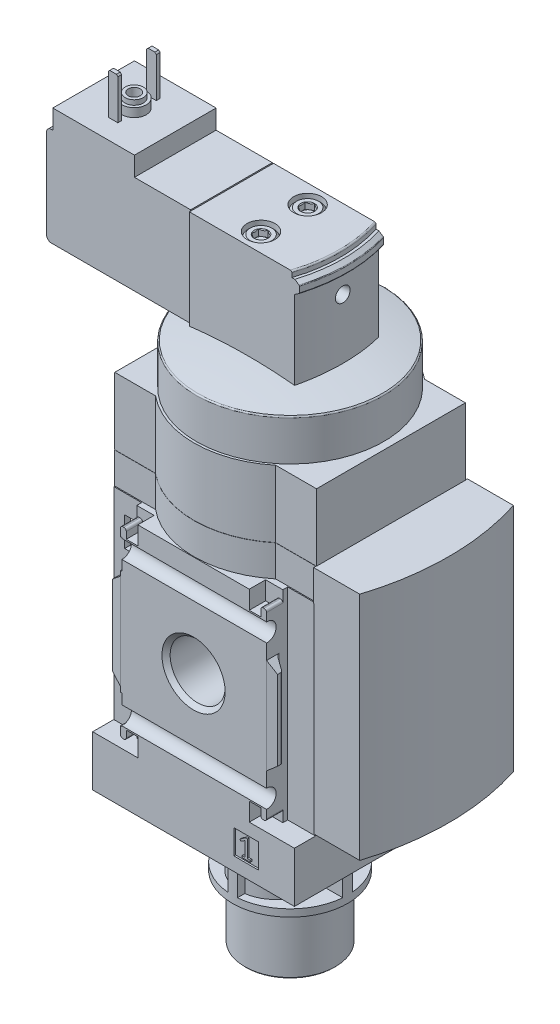
from build123d import *

# Parameters (mm, degrees)
BOSS_EXTRUDE1_DEPTH          = 49.5
BOSS_EXTRUDE2_DEPTH          = 20.1
BOSS_EXTRUDE2_DEPTH_BACK     = 20.1
SKETCH2_W                    = 42
SKETCH2_H                    = 42
SKETCH3_W                    = 42
SKETCH3_H                    = 40.2
BOSS_EXTRUDE3_DEPTH          = 10.5
SKETCH4_W                    = 46
SKETCH4_H                    = 40
CUT_EXTRUDE1_DEPTH           = 14
BOSS_EXTRUDE4_DEPTH          = 13.96
BOSS_EXTRUDE5_DEPTH          = 48
SKETCH9_W                    = 5.1
SKETCH9_H                    = 5.1
CUT_EXTRUDE2_DEPTH           = 0.35
SKETCH10_W                   = 5.1
SKETCH10_H                   = 5.1
CUT_EXTRUDE3_DEPTH           = 0.35
CUT_EXTRUDE4_DEPTH           = 25
CUT_EXTRUDE4_DEPTH_BACK      = 25
CUT_EXTRUDE5_DEPTH           = 25
CUT_EXTRUDE5_DEPTH_BACK      = 25
CUT_EXTRUDE6_DEPTH           = 3.4
CUT_EXTRUDE6_DEPTH_BACK      = 3.4
CUT_EXTRUDE7_DEPTH           = 3.4
CUT_EXTRUDE7_DEPTH_BACK      = 3.4
CUT_EXTRUDE8_DEPTH           = 3.4
CUT_EXTRUDE8_DEPTH_BACK      = 3.4
CUT_EXTRUDE9_DEPTH           = 3.4
CUT_EXTRUDE9_DEPTH_BACK      = 3.4
CUT_EXTRUDE10_DEPTH          = 21
CUT_EXTRUDE10_DEPTH_BACK     = 21
CUT_EXTRUDE11_DEPTH          = 21
CUT_EXTRUDE11_DEPTH_BACK     = 21
SKETCH19_W                   = 4
SKETCH19_H                   = 4
BOSS_EXTRUDE6_DEPTH          = 15
BOSS_EXTRUDE7_DEPTH          = 8.75
BOSS_EXTRUDE7_DEPTH_BACK     = 8.75
CUT_EXTRUDE12_DEPTH          = 25
SKETCH22_W                   = 3
SKETCH22_H                   = 21
CUT_REVOLVE3_ANGLE           = 20
CUT_REVOLVE3_OTHER_WAY_ANGLE = 20
REVOLVE1_ANGLE               = 20
REVOLVE1_OTHER_WAY_ANGLE     = 20
CUT_EXTRUDE13_DEPTH          = 5
CUT_REVOLVE5_ANGLE           = 20
CUT_REVOLVE5_OTHER_WAY_ANGLE = 20
BOSS_EXTRUDE8_DEPTH          = 0.4
BOSS_EXTRUDE8_DEPTH_BACK     = 0.4
BOSS_EXTRUDE9_DEPTH          = 0.4
BOSS_EXTRUDE9_DEPTH_BACK     = 0.4
CUT_EXTRUDE14_DEPTH          = 1.3
CUT_EXTRUDE15_DEPTH          = 1.3
BOSS_EXTRUDE10_DEPTH         = 14
CUT_EXTRUDE16_DEPTH          = 22
CUT_EXTRUDE16_DEPTH_BACK     = 22
SKETCH39_W                   = 3.81
SKETCH39_H                   = 6.07
CUT_EXTRUDE17_DEPTH          = 22
CUT_EXTRUDE17_DEPTH_BACK     = 22
SKETCH40_W                   = 3.81
SKETCH40_H                   = 6.07
CUT_EXTRUDE18_DEPTH          = 11
CUT_EXTRUDE18_DEPTH_BACK     = 11
SKETCH41_W                   = 29
SKETCH41_H                   = 37.9
BOSS_EXTRUDE11_DEPTH         = 19
BOSS_EXTRUDE11_DEPTH_BACK    = 19
BOSS_EXTRUDE12_DEPTH         = 9
BOSS_EXTRUDE13_DEPTH         = 9
SKETCH45_R                   = 3.05
BOSS_EXTRUDE14_DEPTH         = 5


with BuildPart() as part:
    # Sketch1 → Boss-Extrude1 (new body)
    with BuildSketch(Plane(origin=(0, -8, 0), x_dir=(1, 0, 0), z_dir=(0, 1, 0))):
        with BuildLine():
            Line((-21, -15.5), (-12.5, -15.5))
            ThreePointArc((-12.5, -15.5), (0, -20), (12.5, -15.5))
            Line((12.5, -15.5), (21, -15.5))
            Line((21, -15.5), (21, 15.5))
            Line((21, 15.5), (12.5, 15.5))
            ThreePointArc((12.5, 15.5), (0, 20), (-12.5, 15.5))
            Line((-12.5, 15.5), (-21, 15.5))
            Line((-21, 15.5), (-21, -15.5))
        make_face()
    extrude(amount=BOSS_EXTRUDE1_DEPTH)

    # Sketch2 → Boss-Extrude2 (add, two sides: drawn at the far end of the back side and taken through both)
    with BuildSketch(Plane.XY.offset(-BOSS_EXTRUDE2_DEPTH_BACK)):
        Rectangle(SKETCH2_W, SKETCH2_H)
    extrude(amount=BOSS_EXTRUDE2_DEPTH + BOSS_EXTRUDE2_DEPTH_BACK)

    # Sketch3 → Boss-Extrude3 (add)
    with BuildSketch(Plane(origin=(0, -31.5, 0), x_dir=(1, 0, 0), z_dir=(0, 1, 0))):
        Rectangle(SKETCH3_W, SKETCH3_H)
    extrude(amount=BOSS_EXTRUDE3_DEPTH)

    # Sketch4 → Cut-Extrude1 (cut)
    with BuildSketch(Plane(origin=(0, 27.5, 0), x_dir=(1, 0, 0), z_dir=(0, 1, 0))):
        Rectangle(SKETCH4_W, SKETCH4_H)
        with BuildLine():
            Line((-20.58, -15.19), (-12.25, -15.19))
            ThreePointArc((-12.25, -15.19), (0, -19.6), (12.25, -15.19))
            Line((12.25, -15.19), (20.58, -15.19))
            Line((20.58, -15.19), (20.58, 15.19))
            Line((20.58, 15.19), (12.25, 15.19))
            ThreePointArc((12.25, 15.19), (0, 19.6), (-12.25, 15.19))
            Line((-12.25, 15.19), (-20.58, 15.19))
            Line((-20.58, 15.19), (-20.58, -15.19))
        make_face(mode=Mode.SUBTRACT)
    extrude(amount=CUT_EXTRUDE1_DEPTH, mode=Mode.SUBTRACT)

    # Sketch5 → Boss-Extrude4 (add)
    with BuildSketch(Plane(origin=(0, 27.54, 0), x_dir=(1, 0, 0), z_dir=(0, 1, 0))):
        with BuildLine():
            Line((-21, -15.5), (-12.5, -15.5))
            ThreePointArc((-12.5, -15.5), (0, -20), (12.5, -15.5))
            Line((12.5, -15.5), (21, -15.5))
            Line((21, -15.5), (21, 15.5))
            Line((21, 15.5), (12.5, 15.5))
            ThreePointArc((12.5, 15.5), (0, 20), (-12.5, 15.5))
            Line((-12.5, 15.5), (-21, 15.5))
            Line((-21, 15.5), (-21, -15.5))
        make_face()
    extrude(amount=BOSS_EXTRUDE4_DEPTH)

    # Sketch6 → Boss-Extrude5 (add)
    with BuildSketch(Plane(origin=(0, 27.5, 0), x_dir=(1, 0, 0), z_dir=(0, 1, 0))):
        with BuildLine():
            Line((20.9, -16), (30.5, -16))
            ThreePointArc((30.5, -16), (33, 0), (30.5, 16))
            Line((30.5, 16), (20.9, 16))
            Line((20.9, 16), (20.9, -16))
        make_face()
    extrude(amount=-BOSS_EXTRUDE5_DEPTH)

    # Sketch7 → Cut-Revolve1 (revolve, cut)
    with BuildSketch(Plane(origin=(0, 0, 0), x_dir=(0, 0, -1), z_dir=(1, 0, 0))):
        Polygon((-20.1, 0), (-20.1, 6.5785), (-19.244, 5.7225), (-7.799, 5.7225), (-6.943, 6.5785), (-6.943, 0), align=None)
    revolve(axis=Axis((0, 0, 6.943), (0, 0, 1)), mode=Mode.SUBTRACT)

    # Sketch8 → Cut-Revolve2 (revolve, cut)
    with BuildSketch(Plane(origin=(0, 0, 0), x_dir=(0, 0, -1), z_dir=(1, 0, 0))):
        Polygon((6.943, 0), (6.943, 6.5785), (7.799, 5.7225), (19.244, 5.7225), (20.1, 6.5785), (20.1, 0), align=None)
    revolve(axis=Axis((0, 0, -20.1), (0, 0, 1)), mode=Mode.SUBTRACT)

    # Sketch9 → Cut-Extrude2 (cut)
    with BuildSketch(Plane.XY.offset(20.1)):
        with Locations((10.95, -26.14)):
            Rectangle(SKETCH9_W, SKETCH9_H)
        Polygon((9.663200115, -25.02), (9.761292304, -25.275538889), (10.24, -25.062404491), (10.71, -24.78), (10.71, -27.76), (10.1, -27.76), (10.1, -28.14), (11.8, -28.14), (11.8, -27.76), (11.19, -27.76), (11.19, -24.21), (10.82, -24.21), align=None, mode=Mode.SUBTRACT)
    extrude(amount=-CUT_EXTRUDE2_DEPTH, mode=Mode.SUBTRACT)

    # Sketch10 → Cut-Extrude3 (cut)
    with BuildSketch(Plane.XY.offset(-20.1)):
        with Locations((-10.95, -26.14)):
            Rectangle(SKETCH10_W, SKETCH10_H)
        with BuildLine():
            Line((-12.03983262, -25.241503505), (-10.470570303, -27.482642356))
            ThreePointArc((-10.470570303, -27.482642356), (-10.463784424, -27.586174861), (-10.552485507, -27.64))
            Line((-10.552485507, -27.64), (-12.15, -27.64))
            Line((-12.15, -27.64), (-12.15, -28.14))
            Line((-12.15, -28.14), (-9.75, -28.14))
            Line((-9.75, -28.14), (-9.75, -27.64))
            Line((-9.75, -27.64), (-11.575165094, -25.033394109))
            ThreePointArc((-11.575165094, -25.033394109), (-11.592129791, -24.774562847), (-11.370377083, -24.64))
            Line((-11.370377083, -24.64), (-10.75, -24.64))
            ThreePointArc((-10.75, -24.64), (-10.396446609, -24.786446609), (-10.25, -25.14))
            Line((-10.25, -25.14), (-9.75, -25.14))
            ThreePointArc((-9.75, -25.14), (-10.042893219, -24.432893219), (-10.75, -24.14))
            Line((-10.75, -24.14), (-11.466426189, -24.14))
            ThreePointArc((-11.466426189, -24.14), (-12.087333772, -24.516775971), (-12.03983262, -25.241503505))
        make_face(mode=Mode.SUBTRACT)
    extrude(amount=CUT_EXTRUDE3_DEPTH, mode=Mode.SUBTRACT)

    # Sketch11 → Cut-Extrude4 (cut, two sides: drawn at the far end of the back side and taken through both)
    with BuildSketch(Plane(origin=(0, 0, 0), x_dir=(0, 0, -1), z_dir=(1, 0, 0)).offset(-CUT_EXTRUDE4_DEPTH_BACK)):
        with BuildLine():
            Line((21.9, -15), (21.9, 15))
            ThreePointArc((21.9, 15), (18.490033113, 16.153256259), (20.5, 13.166969722))
            Line((20.5, 13.166969722), (20.5, -13.166969722))
            ThreePointArc((20.5, -13.166969722), (18.490033113, -16.153256259), (21.9, -15))
        make_face()
    extrude(amount=CUT_EXTRUDE4_DEPTH + CUT_EXTRUDE4_DEPTH_BACK, mode=Mode.SUBTRACT)

    # Sketch12 → Cut-Extrude5 (cut, two sides: drawn at the far end of the back side and taken through both)
    with BuildSketch(Plane(origin=(0, 0, 0), x_dir=(0, 0, -1), z_dir=(1, 0, 0)).offset(-CUT_EXTRUDE5_DEPTH_BACK)):
        with BuildLine():
            Line((-21.9, 15), (-21.9, -15))
            ThreePointArc((-21.9, -15), (-18.490033113, -16.153256259), (-20.5, -13.166969722))
            Line((-20.5, -13.166969722), (-20.5, 13.166969722))
            ThreePointArc((-20.5, 13.166969722), (-18.490033113, 16.153256259), (-21.9, 15))
        make_face()
    extrude(amount=CUT_EXTRUDE5_DEPTH + CUT_EXTRUDE5_DEPTH_BACK, mode=Mode.SUBTRACT)

    # Sketch13 → Cut-Extrude6 (cut, two sides: drawn at the far end of the back side and taken through both)
    with BuildSketch(Plane.XY.offset(20.1).offset(-CUT_EXTRUDE6_DEPTH_BACK)):
        with BuildLine():
            Line((11.6, 21), (11.6, 17.2))
            Line((11.6, 17.2), (14, 17.2))
            Line((14, 17.2), (14, 18.6))
            ThreePointArc((14, 18.6), (14.146446609, 18.953553391), (14.5, 19.1))
            Line((14.5, 19.1), (14.7, 19.1))
            ThreePointArc((14.7, 19.1), (15.053553391, 18.953553391), (15.2, 18.6))
            Line((15.2, 18.6), (15.2, 9.95))
            Line((15.2, 9.95), (21.5, 4.663672324))
            Line((21.5, 4.663672324), (21.5, -4.663672324))
            Line((21.5, -4.663672324), (15.2, -9.95))
            Line((15.2, -9.95), (15.2, -18.6))
            ThreePointArc((15.2, -18.6), (15.053553391, -18.953553391), (14.7, -19.1))
            Line((14.7, -19.1), (14.5, -19.1))
            ThreePointArc((14.5, -19.1), (14.146446609, -18.953553391), (14, -18.6))
            Line((14, -18.6), (14, -17.2))
            Line((14, -17.2), (11.6, -17.2))
            Line((11.6, -17.2), (11.6, -21))
            Line((11.6, -21), (22, -21))
            Line((22, -21), (22, 21))
            Line((22, 21), (11.6, 21))
        make_face()
    extrude(amount=CUT_EXTRUDE6_DEPTH + CUT_EXTRUDE6_DEPTH_BACK, mode=Mode.SUBTRACT)

    # Sketch14 → Cut-Extrude7 (cut, two sides: drawn at the far end of the back side and taken through both)
    with BuildSketch(Plane.XY.offset(20.1).offset(-CUT_EXTRUDE7_DEPTH_BACK)):
        with BuildLine():
            Line((-22, -21), (-11.6, -21))
            Line((-11.6, -21), (-11.6, -17.2))
            Line((-11.6, -17.2), (-14, -17.2))
            Line((-14, -17.2), (-14, -18.6))
            ThreePointArc((-14, -18.6), (-14.146446609, -18.953553391), (-14.5, -19.1))
            Line((-14.5, -19.1), (-14.7, -19.1))
            ThreePointArc((-14.7, -19.1), (-15.053553391, -18.953553391), (-15.2, -18.6))
            Line((-15.2, -18.6), (-15.2, -9.95))
            Line((-15.2, -9.95), (-21.5, -4.663672324))
            Line((-21.5, -4.663672324), (-21.5, 4.663672324))
            Line((-21.5, 4.663672324), (-15.2, 9.95))
            Line((-15.2, 9.95), (-15.2, 18.6))
            ThreePointArc((-15.2, 18.6), (-15.053553391, 18.953553391), (-14.7, 19.1))
            Line((-14.7, 19.1), (-14.5, 19.1))
            ThreePointArc((-14.5, 19.1), (-14.146446609, 18.953553391), (-14, 18.6))
            Line((-14, 18.6), (-14, 17.2))
            Line((-14, 17.2), (-11.6, 17.2))
            Line((-11.6, 17.2), (-11.6, 21))
            Line((-11.6, 21), (-22, 21))
            Line((-22, 21), (-22, -21))
        make_face()
    extrude(amount=CUT_EXTRUDE7_DEPTH + CUT_EXTRUDE7_DEPTH_BACK, mode=Mode.SUBTRACT)

    # Sketch15 → Cut-Extrude8 (cut, two sides: drawn at the far end of the back side and taken through both)
    with BuildSketch(Plane.XY.offset(-20.1).offset(-CUT_EXTRUDE8_DEPTH_BACK)):
        with BuildLine():
            Line((11.6, 21), (11.6, 17.2))
            Line((11.6, 17.2), (14, 17.2))
            Line((14, 17.2), (14, 18.6))
            ThreePointArc((14, 18.6), (14.146446609, 18.953553391), (14.5, 19.1))
            Line((14.5, 19.1), (14.7, 19.1))
            ThreePointArc((14.7, 19.1), (15.053553391, 18.953553391), (15.2, 18.6))
            Line((15.2, 18.6), (15.2, 9.95))
            Line((15.2, 9.95), (21.5, 4.663672324))
            Line((21.5, 4.663672324), (21.5, -4.663672324))
            Line((21.5, -4.663672324), (15.2, -9.95))
            Line((15.2, -9.95), (15.2, -18.6))
            ThreePointArc((15.2, -18.6), (15.053553391, -18.953553391), (14.7, -19.1))
            Line((14.7, -19.1), (14.5, -19.1))
            ThreePointArc((14.5, -19.1), (14.146446609, -18.953553391), (14, -18.6))
            Line((14, -18.6), (14, -17.2))
            Line((14, -17.2), (11.6, -17.2))
            Line((11.6, -17.2), (11.6, -21))
            Line((11.6, -21), (22, -21))
            Line((22, -21), (22, 21))
            Line((22, 21), (11.6, 21))
        make_face()
    extrude(amount=CUT_EXTRUDE8_DEPTH + CUT_EXTRUDE8_DEPTH_BACK, mode=Mode.SUBTRACT)

    # Sketch16 → Cut-Extrude9 (cut, two sides: drawn at the far end of the back side and taken through both)
    with BuildSketch(Plane.XY.offset(-20.1).offset(-CUT_EXTRUDE9_DEPTH_BACK)):
        with BuildLine():
            Line((-22, -21), (-11.6, -21))
            Line((-11.6, -21), (-11.6, -17.2))
            Line((-11.6, -17.2), (-14, -17.2))
            Line((-14, -17.2), (-14, -18.6))
            ThreePointArc((-14, -18.6), (-14.146446609, -18.953553391), (-14.5, -19.1))
            Line((-14.5, -19.1), (-14.7, -19.1))
            ThreePointArc((-14.7, -19.1), (-15.053553391, -18.953553391), (-15.2, -18.6))
            Line((-15.2, -18.6), (-15.2, -9.95))
            Line((-15.2, -9.95), (-21.5, -4.663672324))
            Line((-21.5, -4.663672324), (-21.5, 4.663672324))
            Line((-21.5, 4.663672324), (-15.2, 9.95))
            Line((-15.2, 9.95), (-15.2, 18.6))
            ThreePointArc((-15.2, 18.6), (-15.053553391, 18.953553391), (-14.7, 19.1))
            Line((-14.7, 19.1), (-14.5, 19.1))
            ThreePointArc((-14.5, 19.1), (-14.146446609, 18.953553391), (-14, 18.6))
            Line((-14, 18.6), (-14, 17.2))
            Line((-14, 17.2), (-11.6, 17.2))
            Line((-11.6, 17.2), (-11.6, 21))
            Line((-11.6, 21), (-22, 21))
            Line((-22, 21), (-22, -21))
        make_face()
    extrude(amount=CUT_EXTRUDE9_DEPTH + CUT_EXTRUDE9_DEPTH_BACK, mode=Mode.SUBTRACT)

    # Sketch17 → Cut-Extrude10 (cut, two sides: drawn at the far end of the back side and taken through both)
    with BuildSketch(Plane(origin=(0, 0, 0), x_dir=(1, 0, 0), z_dir=(0, 1, 0)).offset(-CUT_EXTRUDE10_DEPTH_BACK)):
        with BuildLine():
            Line((-21, 25.1), (-21, 15.7))
            Line((-21, 15.7), (-15.2, 15.7))
            Line((-15.2, 15.7), (-15.2, 17.400104518))
            ThreePointArc((-15.2, 17.400104518), (-15.321561523, 17.82403993), (-15.649303083, 18.119139756))
            Line((-15.649303083, 18.119139756), (-16.919185573, 18.73850283))
            ThreePointArc((-16.919185573, 18.73850283), (-17.124024048, 18.922940221), (-17.2, 19.187899853))
            Line((-17.2, 19.187899853), (-17.2, 19.8))
            Line((-17.2, 19.8), (-15.2, 20.1))
            Line((-15.2, 20.1), (15.2, 20.1))
            Line((15.2, 20.1), (17.2, 19.8))
            Line((17.2, 19.8), (17.2, 19.187899853))
            ThreePointArc((17.2, 19.187899853), (17.124024048, 18.922940221), (16.919185573, 18.73850283))
            Line((16.919185573, 18.73850283), (15.649303083, 18.119139756))
            ThreePointArc((15.649303083, 18.119139756), (15.321561523, 17.82403993), (15.2, 17.400104518))
            Line((15.2, 17.400104518), (15.2, 15.7))
            Line((15.2, 15.7), (21, 15.7))
            Line((21, 15.7), (21, 25.1))
            Line((21, 25.1), (-21, 25.1))
        make_face()
    extrude(amount=CUT_EXTRUDE10_DEPTH + CUT_EXTRUDE10_DEPTH_BACK, mode=Mode.SUBTRACT)

    # Sketch18 → Cut-Extrude11 (cut, two sides: drawn at the far end of the back side and taken through both)
    with BuildSketch(Plane(origin=(0, 0, 0), x_dir=(1, 0, 0), z_dir=(0, 1, 0)).offset(-CUT_EXTRUDE11_DEPTH_BACK)):
        with BuildLine():
            Line((-21, -25.1), (21, -25.1))
            Line((21, -25.1), (21, -15.7))
            Line((21, -15.7), (15.2, -15.7))
            Line((15.2, -15.7), (15.2, -17.400104518))
            ThreePointArc((15.2, -17.400104518), (15.321561523, -17.82403993), (15.649303083, -18.119139756))
            Line((15.649303083, -18.119139756), (16.919185573, -18.73850283))
            ThreePointArc((16.919185573, -18.73850283), (17.124024048, -18.922940221), (17.2, -19.187899853))
            Line((17.2, -19.187899853), (17.2, -19.8))
            Line((17.2, -19.8), (15.2, -20.1))
            Line((15.2, -20.1), (-15.2, -20.1))
            Line((-15.2, -20.1), (-17.2, -19.8))
            Line((-17.2, -19.8), (-17.2, -19.187899853))
            ThreePointArc((-17.2, -19.187899853), (-17.124024048, -18.922940221), (-16.919185573, -18.73850283))
            Line((-16.919185573, -18.73850283), (-15.649303083, -18.119139756))
            ThreePointArc((-15.649303083, -18.119139756), (-15.321561523, -17.82403993), (-15.2, -17.400104518))
            Line((-15.2, -17.400104518), (-15.2, -15.7))
            Line((-15.2, -15.7), (-21, -15.7))
            Line((-21, -15.7), (-21, -25.1))
        make_face()
    extrude(amount=CUT_EXTRUDE11_DEPTH + CUT_EXTRUDE11_DEPTH_BACK, mode=Mode.SUBTRACT)

    # Sketch19 → Boss-Extrude6 (add)
    with BuildSketch(Plane(origin=(0, 40, 0), x_dir=(1, 0, 0), z_dir=(0, 1, 0))):
        Rectangle(SKETCH19_W, SKETCH19_H)
    extrude(amount=BOSS_EXTRUDE6_DEPTH)

    # Sketch20 → Boss-Extrude7 (add, two sides: drawn at the far end of the back side and taken through both)
    with BuildSketch(Plane.XY.offset(-BOSS_EXTRUDE7_DEPTH_BACK)):
        with BuildLine():
            Line((-42.2, 70.7), (-42.2, 52.2))
            ThreePointArc((-42.2, 52.2), (-41.907106781, 51.492893219), (-41.2, 51.2))
            Line((-41.2, 51.2), (-12.2, 51.2))
            Line((-12.2, 51.2), (-12.2, 49.95))
            Line((-12.2, 49.95), (11, 49.95))
            Line((11, 49.95), (11, 71.45))
            Line((11, 71.45), (-12.2, 71.45))
            Line((-12.2, 71.45), (-12.2, 71.7))
            Line((-12.2, 71.7), (-23.9, 71.7))
            Line((-23.9, 71.7), (-23.9, 75.7))
            Line((-23.9, 75.7), (-40.9, 75.7))
            Line((-40.9, 75.7), (-40.9, 71.7))
            Line((-40.9, 71.7), (-41.2, 71.7))
            ThreePointArc((-41.2, 71.7), (-41.907106781, 71.407106781), (-42.2, 70.7))
        make_face()
    extrude(amount=BOSS_EXTRUDE7_DEPTH + BOSS_EXTRUDE7_DEPTH_BACK)

    # Sketch21 → Cut-Extrude12 (cut)
    with BuildSketch(Plane(origin=(0, 51.2, 0), x_dir=(1, 0, 0), z_dir=(0, 1, 0))):
        Polygon((-52.2, 18.5), (-52.2, -18.5), (-12.2, -18.5), (-12.2, -8.5), (-42.2, -8.5), (-42.2, 8.5), (-12.2, 8.5), (-12.2, 18.5), align=None)
    extrude(amount=CUT_EXTRUDE12_DEPTH, mode=Mode.SUBTRACT)

    # Sketch22 → Cut-Revolve3 (revolve, cut)
    with BuildSketch(Plane.XY):
        with Locations((12.5, 61.2)):
            Rectangle(SKETCH22_W, SKETCH22_H)
    revolve(axis=Axis((-19, 50.7, 0), (0, -1, 0)), revolution_arc=CUT_REVOLVE3_ANGLE, mode=Mode.SUBTRACT)

    # Sketch22 → Cut-Revolve3 other way (revolve, cut)
    with BuildSketch(Plane.XY):
        with Locations((12.5, 61.2)):
            Rectangle(SKETCH22_W, SKETCH22_H)
    revolve(axis=Axis((-19, 50.7, 0), (0, 1, 0)), revolution_arc=CUT_REVOLVE3_OTHER_WAY_ANGLE, mode=Mode.SUBTRACT)

    # Sketch23 → Revolve1 (revolve)
    with BuildSketch(Plane.XY):
        with BuildLine():
            Line((9, 70.3), (9, 67.5))
            Line((9, 67.5), (11, 67.5))
            Line((11, 67.5), (11.914715287, 68.140490539))
            ThreePointArc((11.914715287, 68.140490539), (11.977402167, 68.211971226), (12, 68.304320948))
            Line((12, 68.304320948), (12, 69.495679052))
            ThreePointArc((12, 69.495679052), (11.977402167, 69.588028774), (11.914715287, 69.659509461))
            Line((11.914715287, 69.659509461), (11, 70.3))
            Line((11, 70.3), (9, 70.3))
        make_face()
    revolve(axis=Axis((-18.5, 68.304320948, 0), (0, -1, 0)), revolution_arc=REVOLVE1_ANGLE)

    # Sketch23 → Revolve1 other way (revolve)
    with BuildSketch(Plane.XY):
        with BuildLine():
            Line((9, 70.3), (9, 67.5))
            Line((9, 67.5), (11, 67.5))
            Line((11, 67.5), (11.914715287, 68.140490539))
            ThreePointArc((11.914715287, 68.140490539), (11.977402167, 68.211971226), (12, 68.304320948))
            Line((12, 68.304320948), (12, 69.495679052))
            ThreePointArc((12, 69.495679052), (11.977402167, 69.588028774), (11.914715287, 69.659509461))
            Line((11.914715287, 69.659509461), (11, 70.3))
            Line((11, 70.3), (9, 70.3))
        make_face()
    revolve(axis=Axis((-18.5, 68.304320948, 0), (0, 1, 0)), revolution_arc=REVOLVE1_OTHER_WAY_ANGLE)

    # Sketch24 → Cut-Extrude13 (cut)
    with BuildSketch(Plane(origin=(0, 70.7, 0), x_dir=(1, 0, 0), z_dir=(0, 1, 0))):
        Polygon((-3, -13.75), (22, -13.75), (22, 13.75), (-3, 13.75), (-3, 8.75), (17, 8.75), (17, -8.75), (-3, -8.75), align=None)
    extrude(amount=-CUT_EXTRUDE13_DEPTH, mode=Mode.SUBTRACT)

    # Sketch25 → Revolve2 (revolve)
    with BuildSketch(Plane.XY):
        with BuildLine():
            Line((19.5, 49.793463395), (19.5, 41.5))
            Line((19.5, 41.5), (0, 41.5))
            Line((0, 41.5), (0, 51.959675775))
            ThreePointArc((0, 51.959675775), (9.674264478, 51.490618737), (19.25777332, 50.087847911))
            ThreePointArc((19.25777332, 50.087847911), (19.431659228, 49.984078195), (19.5, 49.793463395))
        make_face()
    revolve(axis=Axis((0, 41.5, 0), (0, 1, 0)))

    # Sketch26 → Cut-Revolve4 (revolve, cut)
    with BuildSketch(Plane.XY):
        Polygon((11, 63.8), (11, 62.268365096), (6, 63.15), (6, 63.8), align=None)
    revolve(axis=Axis((6, 63.8, 0), (1, 0, 0)), mode=Mode.SUBTRACT)

    # Sketch27 → Cut-Revolve5 (revolve, cut)
    with BuildSketch(Plane.XY):
        with BuildLine():
            Line((10.5, 71.15), (10.5, 70.25))
            Line((10.5, 70.25), (15.5, 70.25))
            Line((15.5, 70.25), (15.5, 71.45))
            Line((15.5, 71.45), (10.2, 71.45))
            ThreePointArc((10.2, 71.45), (10.412132034, 71.362132034), (10.5, 71.15))
        make_face()
    revolve(axis=Axis((-18, 70.25, 0), (0, -1, 0)), revolution_arc=CUT_REVOLVE5_ANGLE, mode=Mode.SUBTRACT)

    # Sketch27 → Cut-Revolve5 other way (revolve, cut)
    with BuildSketch(Plane.XY):
        with BuildLine():
            Line((10.5, 71.15), (10.5, 70.25))
            Line((10.5, 70.25), (15.5, 70.25))
            Line((15.5, 70.25), (15.5, 71.45))
            Line((15.5, 71.45), (10.2, 71.45))
            ThreePointArc((10.2, 71.45), (10.412132034, 71.362132034), (10.5, 71.15))
        make_face()
    revolve(axis=Axis((-18, 70.25, 0), (0, 1, 0)), revolution_arc=CUT_REVOLVE5_OTHER_WAY_ANGLE, mode=Mode.SUBTRACT)

    # Sketch28 → Boss-Extrude8 (add, two sides: drawn at the far end of the back side and taken through both)
    with BuildSketch(Plane.XY.offset(4).offset(-BOSS_EXTRUDE8_DEPTH_BACK)):
        Polygon((-33.45, 84), (-33.45, 75.7), (-31.45, 75.7), (-31.45, 84), (-31.75, 84.3), (-33.15, 84.3), align=None)
    extrude(amount=BOSS_EXTRUDE8_DEPTH + BOSS_EXTRUDE8_DEPTH_BACK)

    # Sketch29 → Boss-Extrude9 (add, two sides: drawn at the far end of the back side and taken through both)
    with BuildSketch(Plane.XY.offset(-4).offset(-BOSS_EXTRUDE9_DEPTH_BACK)):
        Polygon((-33.45, 84), (-33.45, 75.7), (-31.45, 75.7), (-31.45, 84), (-31.75, 84.3), (-33.15, 84.3), align=None)
    extrude(amount=BOSS_EXTRUDE9_DEPTH + BOSS_EXTRUDE9_DEPTH_BACK)

    # Sketch30 → Revolve3 (revolve)
    with BuildSketch(Plane.XY):
        Polygon((-32.45, 78.5), (-30.55, 78.5), (-30.55, 77.5), (-29.95, 77.5), (-29.95, 75.7), (-32.45, 75.7), align=None)
    revolve(axis=Axis((-32.45, 75.7, 0), (0, 1, 0)))

    # Sketch31 → Cut-Revolve6 (revolve, cut)
    with BuildSketch(Plane.XY):
        Polygon((-32.45, 78.5), (-31.2, 78.5), (-31.2, 76), (-31.4435, 75.7565), (-31.4435, 72.9), (-32.45, 72.9), align=None)
    revolve(axis=Axis((-32.45, 72.9, 0), (0, 1, 0)), mode=Mode.SUBTRACT)

    # Sketch32 → Cut-Revolve7 (revolve, cut)
    with BuildSketch(Plane(origin=(-1.2, 0, 0), x_dir=(0, 0, -1), z_dir=(1, 0, 0))):
        Polygon((4.85, 71.45), (7.75, 71.45), (7.75, 67.95), (7.6, 67.95), (7.6, 70.45), (7.1, 70.95), (6.293375673, 70.95), (6.1, 70.756624327), (6.1, 69.65), (4.85, 68.928312164), align=None)
    revolve(axis=Axis((-1.2, 68.928312164, -4.85), (0, 1, 0)), mode=Mode.SUBTRACT)

    # Sketch33 → Cut-Revolve8 (revolve, cut)
    with BuildSketch(Plane(origin=(-1.2, 0, 0), x_dir=(0, 0, -1), z_dir=(1, 0, 0))):
        Polygon((-4.85, 71.45), (-1.95, 71.45), (-1.95, 67.95), (-2.1, 67.95), (-2.1, 70.45), (-2.6, 70.95), (-3.406624327, 70.95), (-3.6, 70.756624327), (-3.6, 69.65), (-4.85, 68.928312164), align=None)
    revolve(axis=Axis((-1.2, 68.928312164, 4.85), (0, 1, 0)), mode=Mode.SUBTRACT)

    # Sketch34 → Cut-Extrude14 (cut)
    with BuildSketch(Plane(origin=(0, 70.95, 0), x_dir=(1, 0, 0), z_dir=(0, 1, 0))):
        Polygon((-2.45, 4.128312164), (-1.2, 3.406624327), (0.05, 4.128312164), (0.05, 5.571687836), (-1.2, 6.293375673), (-2.45, 5.571687836), align=None)
    extrude(amount=-CUT_EXTRUDE14_DEPTH, mode=Mode.SUBTRACT)

    # Sketch35 → Cut-Extrude15 (cut)
    with BuildSketch(Plane(origin=(0, 70.95, 0), x_dir=(1, 0, 0), z_dir=(0, 1, 0))):
        Polygon((-2.45, -5.571687836), (-1.2, -6.293375673), (0.05, -5.571687836), (0.05, -4.128312164), (-1.2, -3.406624327), (-2.45, -4.128312164), align=None)
    extrude(amount=-CUT_EXTRUDE15_DEPTH, mode=Mode.SUBTRACT)

    # Sketch36 → Revolve4 (revolve)
    with BuildSketch(Plane.XY):
        Polygon((0, -31.5), (14.7, -31.5), (14.7, -32.7), (8.5, -36.279571669), (8.5, -44), (12, -44), (12, -45.5), (9.425, -46.189969171), (9.425, -58.2), (9.125, -58.5), (0, -58.5), align=None)
    revolve(axis=Axis((0, -58.5, 0), (0, 1, 0)))

    # Sketch37 → Boss-Extrude10 (add)
    with BuildSketch(Plane(origin=(0, -44, 0), x_dir=(1, 0, 0), z_dir=(0, 1, 0))):
        with BuildLine():
            Line((-11.958260743, -1), (-7.228416147, -1))
            ThreePointArc((-7.228416147, -1), (-6.258773238, -7.132524356), (-1, -10.433034374))
            Line((-1, -10.433034374), (-1, -11.958260743))
            ThreePointArc((-1, -11.958260743), (0, -12), (1, -11.958260743))
            Line((1, -11.958260743), (1, -10.433034374))
            ThreePointArc((1, -10.433034374), (6.258773238, -7.132524356), (7.228416147, -1))
            Line((7.228416147, -1), (11.958260743, -1))
            ThreePointArc((11.958260743, -1), (12, 0), (11.958260743, 1))
            Line((11.958260743, 1), (1, 1))
            Line((1, 1), (1, 11.958260743))
            ThreePointArc((1, 11.958260743), (0, 12), (-1, 11.958260743))
            Line((-1, 11.958260743), (-1, 1))
            Line((-1, 1), (-11.958260743, 1))
            ThreePointArc((-11.958260743, 1), (-12, 0), (-11.958260743, -1))
        make_face()
    extrude(amount=BOSS_EXTRUDE10_DEPTH)

    # Sketch38 → Cut-Revolve9 (revolve, cut)
    with BuildSketch(Plane.XY):
        Polygon((0, -45.5), (5.7225, -45.5), (5.7225, -57.644), (6.5785, -58.5), (6.5785, -59.5), (0, -59.5), align=None)
    revolve(axis=Axis((0, -59.5, 0), (0, 1, 0)), mode=Mode.SUBTRACT)

    # Sketch39 → Cut-Extrude16 (cut, two sides: drawn at the far end of the back side and taken through both)
    with BuildSketch(Plane.XY.offset(-CUT_EXTRUDE16_DEPTH_BACK)):
        with Locations((-16.825, 14.005)):
            Rectangle(SKETCH39_W, SKETCH39_H)
    extrude(amount=CUT_EXTRUDE16_DEPTH + CUT_EXTRUDE16_DEPTH_BACK, mode=Mode.SUBTRACT)

    # Sketch40 → Cut-Extrude17 (cut, two sides: drawn at the far end of the back side and taken through both)
    with BuildSketch(Plane.XY.offset(-CUT_EXTRUDE17_DEPTH_BACK)):
        with Locations((-16.825, -13.995)):
            Rectangle(SKETCH40_W, SKETCH40_H)
    extrude(amount=CUT_EXTRUDE17_DEPTH + CUT_EXTRUDE17_DEPTH_BACK, mode=Mode.SUBTRACT)

    # Sketch41 → Cut-Extrude18 (cut, two sides: drawn at the far end of the back side and taken through both)
    with BuildSketch(Plane(origin=(-21, 0, 0), x_dir=(0, 0, -1), z_dir=(1, 0, 0)).offset(-CUT_EXTRUDE18_DEPTH_BACK)):
        Rectangle(SKETCH41_W, SKETCH41_H)
    extrude(amount=CUT_EXTRUDE18_DEPTH + CUT_EXTRUDE18_DEPTH_BACK, mode=Mode.SUBTRACT)

    # Sketch42 → Boss-Extrude11 (add, two sides: drawn at the far end of the back side and taken through both)
    with BuildSketch(Plane(origin=(0, 0, 0), x_dir=(1, 0, 0), z_dir=(0, 1, 0)).offset(-BOSS_EXTRUDE11_DEPTH_BACK)):
        with BuildLine():
            Line((-11.489125293, -14.5), (-10, -14.5))
            Line((-10, -14.5), (-10, 14.5))
            Line((-10, 14.5), (-11.489125293, 14.5))
            ThreePointArc((-11.489125293, 14.5), (-18.5, 0), (-11.489125293, -14.5))
        make_face()
    extrude(amount=BOSS_EXTRUDE11_DEPTH + BOSS_EXTRUDE11_DEPTH_BACK)

    # Sketch43 → Boss-Extrude12 (add)
    with BuildSketch(Plane(origin=(-19.9, 0, 0), x_dir=(0, 0, -1), z_dir=(1, 0, 0))):
        with BuildLine():
            Line((8.8, -21.3), (14.6, -21.3))
            Line((14.6, -21.3), (14.6, -17.1))
            Line((14.6, -17.1), (13.163330765, -17.1))
            ThreePointArc((13.163330765, -17.1), (10.799161363, -15.309186489), (8.8, -17.5))
            Line((8.8, -17.5), (8.8, -21.3))
        make_face()
    extrude(amount=BOSS_EXTRUDE12_DEPTH)

    # Sketch44 → Boss-Extrude13 (add)
    with BuildSketch(Plane(origin=(-19.9, 0, 0), x_dir=(0, 0, -1), z_dir=(1, 0, 0))):
        with BuildLine():
            Line((-14.6, 17.1), (-13.163330765, 17.1))
            ThreePointArc((-13.163330765, 17.1), (-10.799161363, 15.309186489), (-8.8, 17.5))
            Line((-8.8, 17.5), (-8.8, 21.3))
            Line((-8.8, 21.3), (-14.6, 21.3))
            Line((-14.6, 21.3), (-14.6, 17.1))
        make_face()
    extrude(amount=BOSS_EXTRUDE13_DEPTH)

    # Sketch45 → Boss-Extrude14 (add)
    with BuildSketch(Plane(origin=(-18, 0, 0), x_dir=(0, 0, -1), z_dir=(1, 0, 0))):
        with Locations((8.6, 6)):
            Circle(SKETCH45_R)
    extrude(amount=BOSS_EXTRUDE14_DEPTH)


solid = part.part
